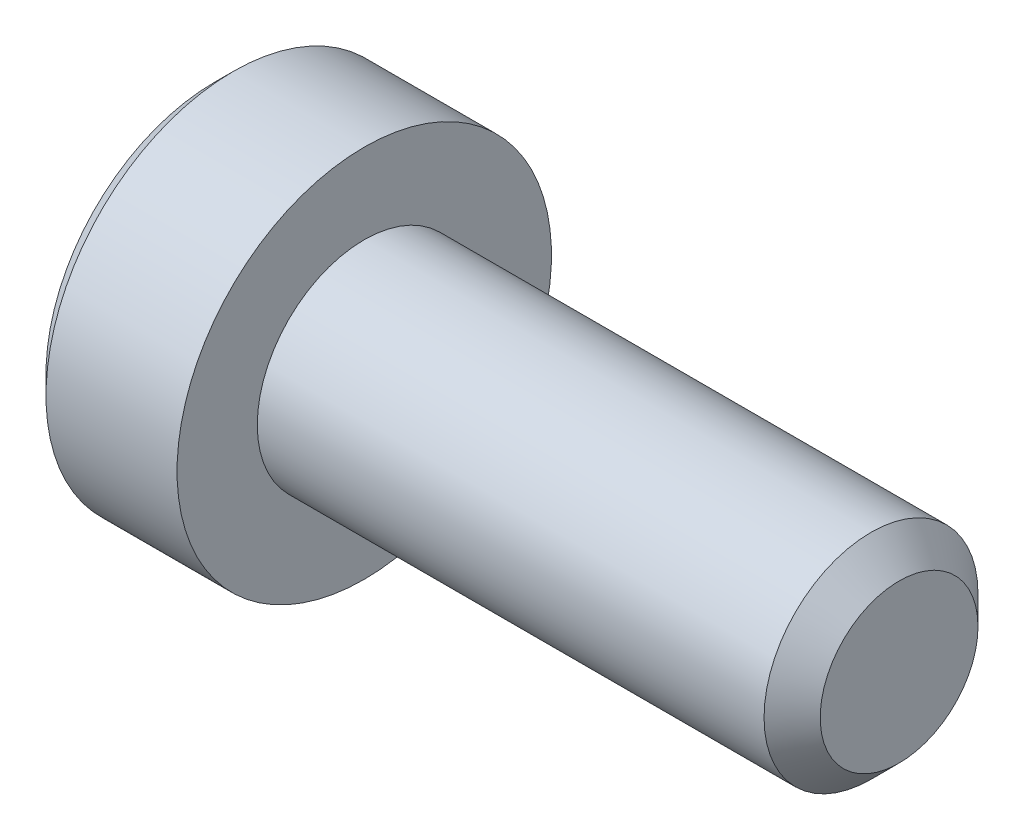
from build123d import *

# Parameters (mm, degrees)
SKETCH2_R           = 2
BOSS_EXTRUDE1_DEPTH = 10
CHAMFER1_SIZE       = 0.525
CUT_EXTRUDE1_DEPTH  = 2.42


with BuildPart() as part:
    # Sketch2 → Boss-Extrude1 (new body)
    with BuildSketch(Plane(origin=(5, 0, 0), x_dir=(0, 0, -1), z_dir=(1, 0, 0))):
        Circle(SKETCH2_R)
    extrude(amount=-BOSS_EXTRUDE1_DEPTH)

    # Chamfer1
    chamfer1_edges = [part.edges().sort_by_distance(p)[0] for p in [
        (5, 0, 2),
    ]]
    chamfer(chamfer1_edges, length=CHAMFER1_SIZE)

    # Sketch6 → Revolve1 (revolve)
    with BuildSketch(Plane.XY):
        Polygon((-7.45, 3.5), (-7.8, 3.15), (-7.8, 0), (-5, 0), (-5, 3.5), align=None)
    revolve(axis=Axis((-5, 0, 0), (-1, 0, 0)))

    # Sketch4 → Cut-Extrude1 (cut)
    with BuildSketch(Plane(origin=(-7.8, 0, 0), x_dir=(0, 0, -1), z_dir=(1, 0, 0))):
        Polygon((0, 1.443375673), (-1.25, 0.721687836), (-1.25, -0.721687836), (0, -1.443375673), (1.25, -0.721687836), (1.25, 0.721687836), align=None)
    extrude(amount=CUT_EXTRUDE1_DEPTH, mode=Mode.SUBTRACT)

    # Cut-Extrude2 cone 1 section (through the dimple's axis) → Cut-Extrude2 (revolve, cut)
    with BuildSketch(Plane(origin=(-7.8, 0, 0), x_dir=(0, 0, 1), z_dir=(0, 1, 0))):
        Polygon((0, 0), (1.443375673, 0), (0, 1.443375673), align=None)
    revolve(axis=Axis((-7.8, 0, 0), (1, 0, 0)), mode=Mode.SUBTRACT)


solid = part.part
